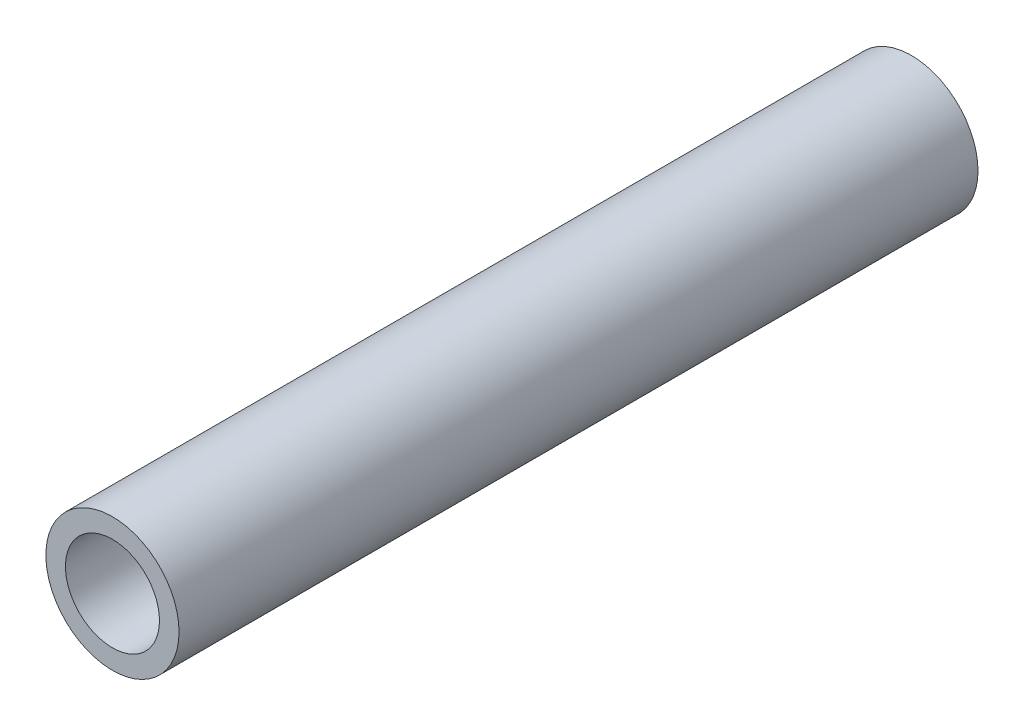
from build123d import *

# Parameters (mm, degrees)
SKETCH1_R           = 6.35
SKETCH1_R_2         = 4.4831
BOSS_EXTRUDE1_DEPTH = 76.2


with BuildPart() as part:
    # Sketch1 → Boss-Extrude1 (new body)
    with BuildSketch(Plane.XY):
        Circle(SKETCH1_R)
        Circle(SKETCH1_R_2, mode=Mode.SUBTRACT)
    extrude(amount=BOSS_EXTRUDE1_DEPTH)


solid = part.part
